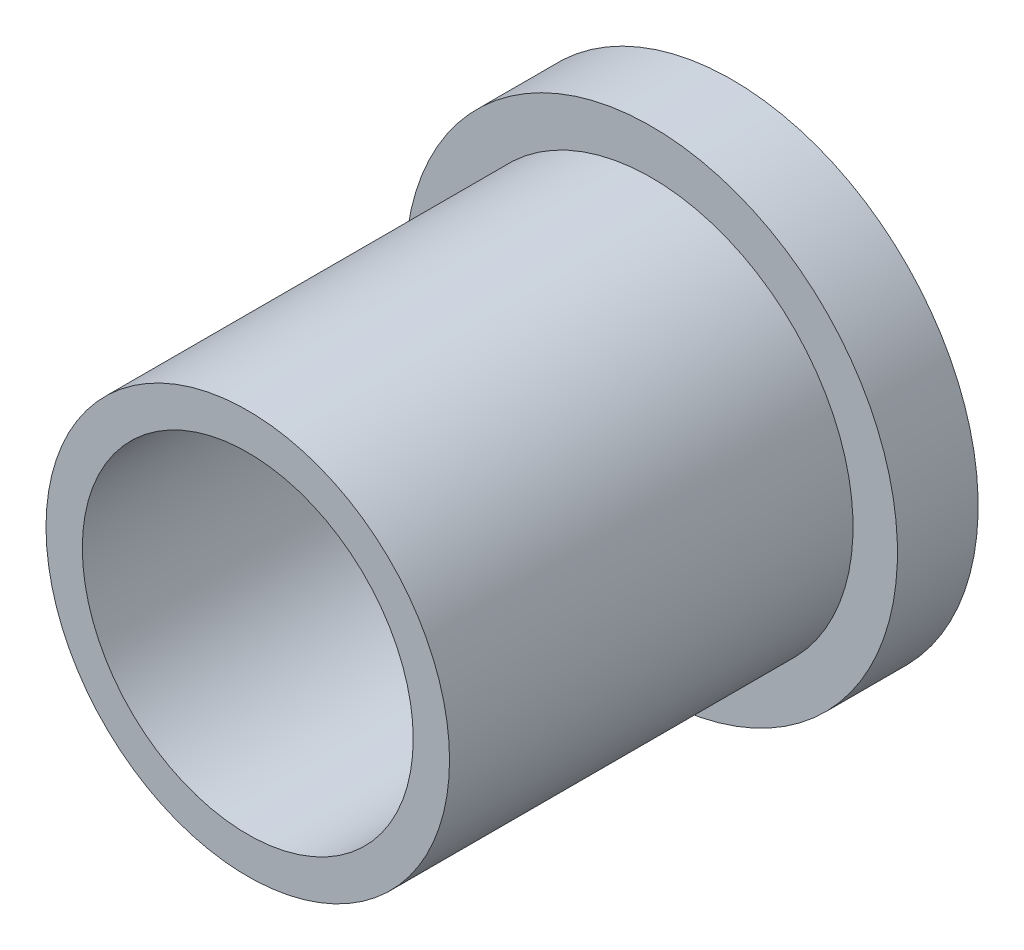
from build123d import *

# Parameters (mm, degrees)
SKETCH1_R           = 5
SKETCH1_R_2         = 4.1
BOSS_EXTRUDE1_DEPTH = 10
SKETCH2_R           = 6.1
SKETCH2_R_2         = 4.1
EXTRUDE_THIN1_DEPTH = 2


with BuildPart() as part:
    # Sketch1 → Boss-Extrude1 (new body)
    with BuildSketch(Plane.XY):
        Circle(SKETCH1_R)
        Circle(SKETCH1_R_2, mode=Mode.SUBTRACT)
    extrude(amount=BOSS_EXTRUDE1_DEPTH)

    # Sketch2 → Extrude-Thin1 (add)
    with BuildSketch(Plane(origin=(0, 0, 0), x_dir=(-1, 0, 0), z_dir=(0, 0, -1))):
        Circle(SKETCH2_R)
        Circle(SKETCH2_R_2, mode=Mode.SUBTRACT)
    extrude(amount=EXTRUDE_THIN1_DEPTH)


solid = part.part
